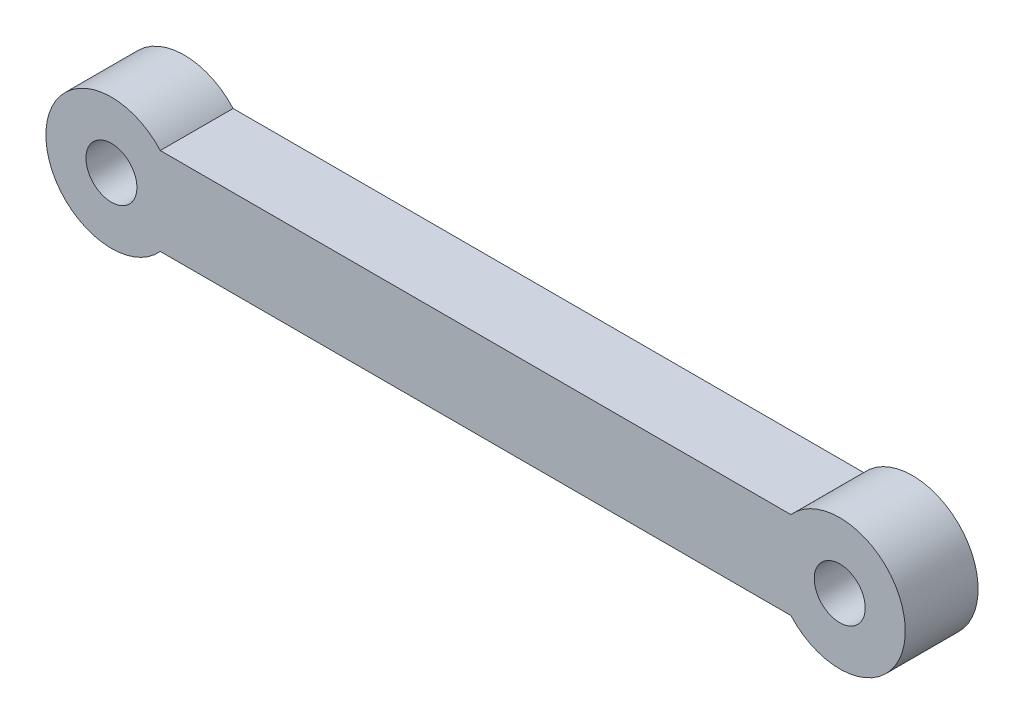
from build123d import *

# Parameters (mm, degrees)
ESBO_O1_R                = 1.75
RESSALTO_EXTRUS_O1_DEPTH = 5


with BuildPart() as part:
    # Esboço1 → Ressalto-extrusão1 (new body)
    with BuildSketch(Plane.XY):
        with BuildLine():
            Line((-3.354101966, 3), (-46.645898034, 3))
            ThreePointArc((-46.645898034, 3), (-54.5, 0), (-46.645898034, -3))
            Line((-46.645898034, -3), (-3.354101966, -3))
            ThreePointArc((-3.354101966, -3), (4.5, 0), (-3.354101966, 3))
        make_face()
        Circle(ESBO_O1_R, mode=Mode.SUBTRACT)
        with Locations((-50, 0)):
            Circle(ESBO_O1_R, mode=Mode.SUBTRACT)
    extrude(amount=RESSALTO_EXTRUS_O1_DEPTH)


solid = part.part
